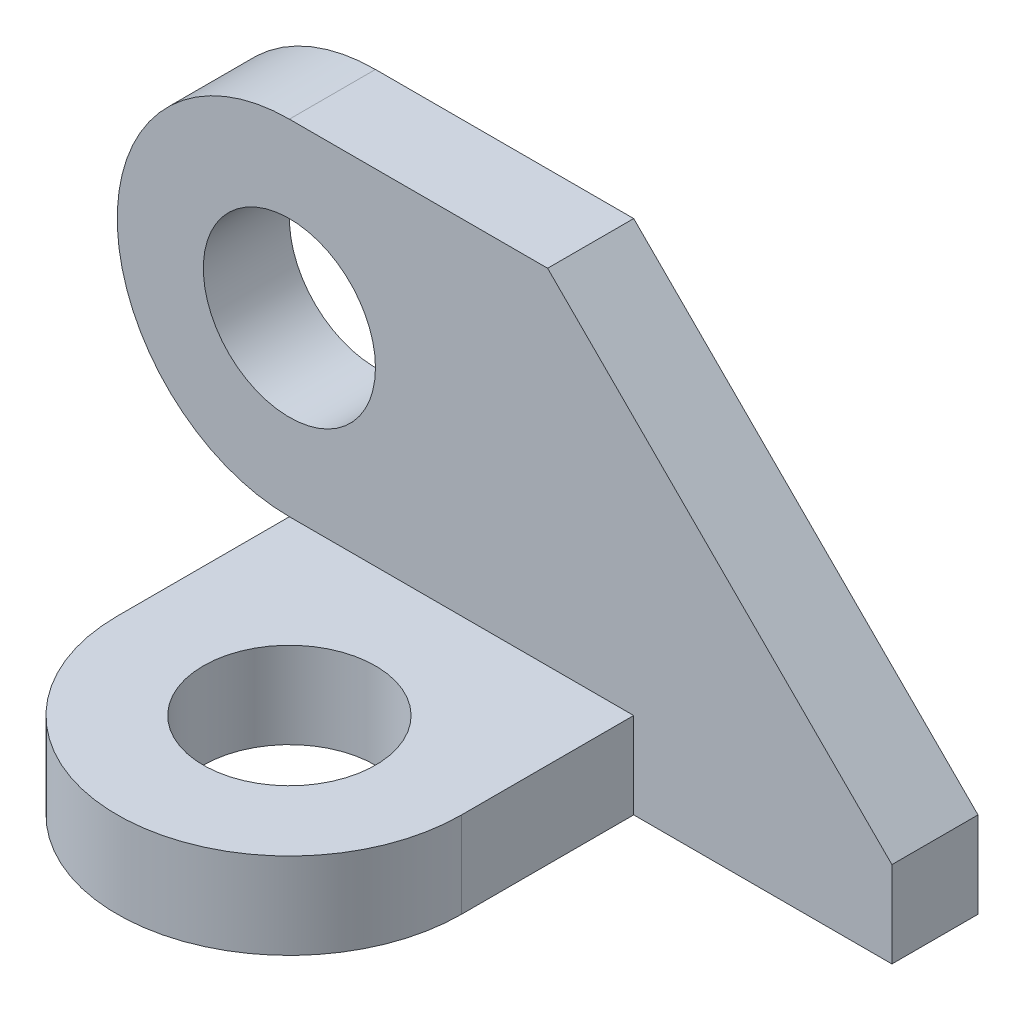
from build123d import *

# Parameters (mm, degrees)
SKETCH_1_R      = 5
EXTRUDE_1_DEPTH = 5
EXTRUDE_START   = -15
SKETCH_2_R      = 5
EXTRUDE_2_DEPTH = 5


with BuildPart() as part:
    # 草圖1 → 填料-伸長1 (new body)
    with BuildSketch(Plane.XY):
        with BuildLine():
            Line((0, 10), (15, 10))
            Line((15, 10), (35, -10))
            Line((35, -10), (35, -15))
            Line((35, -15), (0, -15))
            Line((0, -15), (0, -10))
            ThreePointArc((0, -10), (-10, 0), (0, 10))
        make_face()
        Circle(SKETCH_1_R, mode=Mode.SUBTRACT)
    extrude(amount=EXTRUDE_1_DEPTH)

    # 草圖2 → 填料-伸長2 (add)
    with BuildSketch(Plane(origin=(0, 0, 0), x_dir=(1, 0, 0), z_dir=(0, 1, 0)).offset(EXTRUDE_START)):
        with BuildLine():
            Line((0, -15), (0, -5))
            Line((0, -5), (20, -5))
            Line((20, -5), (20, -15))
            ThreePointArc((20, -15), (10, -25), (0, -15))
        make_face()
        with Locations((10, -15)):
            Circle(SKETCH_2_R, mode=Mode.SUBTRACT)
    extrude(amount=EXTRUDE_2_DEPTH)


solid = part.part
